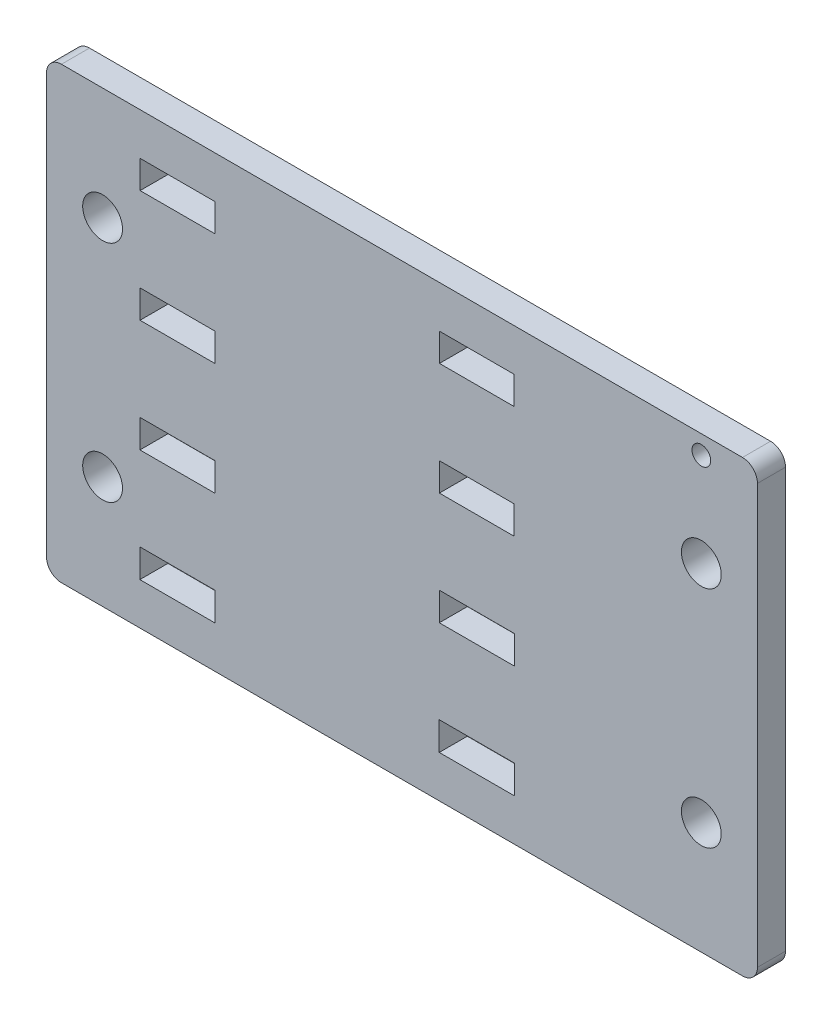
from build123d import *

# Parameters (mm, degrees)
SKETCH1_W                   = 120.65
SKETCH1_H                   = 76.2
BOSS_EXTRUDE1_DEPTH         = 4.7625
SKETCH2_W                   = 12.6746
SKETCH2_H                   = 4.7371
SKETCH2_W_2                 = 12.7
SKETCH2_H_2                 = 4.7625
SKETCH2_W_3                 = 12.7254
SKETCH2_H_3                 = 4.7879
SKETCH2_W_4                 = 12.7508
SKETCH2_H_4                 = 4.8133
CUT_EXTRUDE1_DEPTH          = 5.7625
F_1_4_CLEARANCE_HOLE1_D     = 6.7564
F_1_4_CLEARANCE_HOLE1_DEPTH = 25.4
F_1_4_CLEARANCE_HOLE1_TIP   = 2.029827343
SKETCH6_R                   = 1.5875
CUT_EXTRUDE2_DEPTH          = 5.7625
FILLET1_R                   = 2.54


with BuildPart() as part:
    # Sketch1 → Boss-Extrude1 (new body)
    with BuildSketch(Plane.XY):
        Rectangle(SKETCH1_W, SKETCH1_H)
    extrude(amount=BOSS_EXTRUDE1_DEPTH)

    # Sketch2 → Cut-Extrude1 (cut, through all)
    with BuildSketch(Plane.XY.offset(4.7625)):
        with Locations((-38.1, 28.575)):
            Rectangle(SKETCH2_W, SKETCH2_H)
        with Locations((12.7, 28.575)):
            Rectangle(SKETCH2_W, SKETCH2_H)
        with Locations((-38.1, 9.525)):
            Rectangle(SKETCH2_W_2, SKETCH2_H_2)
        with Locations((12.7, 9.525)):
            Rectangle(SKETCH2_W_2, SKETCH2_H_2)
        with Locations((-38.1, -9.525)):
            Rectangle(SKETCH2_W_3, SKETCH2_H_3)
        with Locations((12.7, -9.525)):
            Rectangle(SKETCH2_W_3, SKETCH2_H_3)
        with Locations((-38.1, -28.575)):
            Rectangle(SKETCH2_W_4, SKETCH2_H_4)
        with Locations((12.7, -28.575)):
            Rectangle(SKETCH2_W_4, SKETCH2_H_4)
    extrude(amount=-CUT_EXTRUDE1_DEPTH, mode=Mode.SUBTRACT)

    # 1/4 Clearance Hole1
    with Locations(Plane.XY.offset(4.7625)):
        with Locations((-50.8, 19.05), (50.8, 19.05), (-50.8, -19.05), (50.8, -19.05)):
            Hole(F_1_4_CLEARANCE_HOLE1_D / 2, depth=F_1_4_CLEARANCE_HOLE1_DEPTH)
            with Locations((0, 0, -(F_1_4_CLEARANCE_HOLE1_DEPTH + F_1_4_CLEARANCE_HOLE1_TIP / 2))):  # 118° drill point
                Cone(0, F_1_4_CLEARANCE_HOLE1_D / 2, F_1_4_CLEARANCE_HOLE1_TIP, mode=Mode.SUBTRACT)

    # Sketch6 → Cut-Extrude2 (cut, through all)
    with BuildSketch(Plane.XY.offset(4.7625)):
        with Locations((50.8, 34.925)):
            Circle(SKETCH6_R)
    extrude(amount=-CUT_EXTRUDE2_DEPTH, mode=Mode.SUBTRACT)

    # Fillet1
    fillet1_edges = [part.edges().sort_by_distance(p)[0] for p in [
        (-60.325, 38.1, 2.38125),
        (60.325, 38.1, 2.38125),
        (60.325, -38.1, 2.38125),
        (-60.325, -38.1, 2.38125),
    ]]
    fillet(fillet1_edges, radius=FILLET1_R)


solid = part.part
